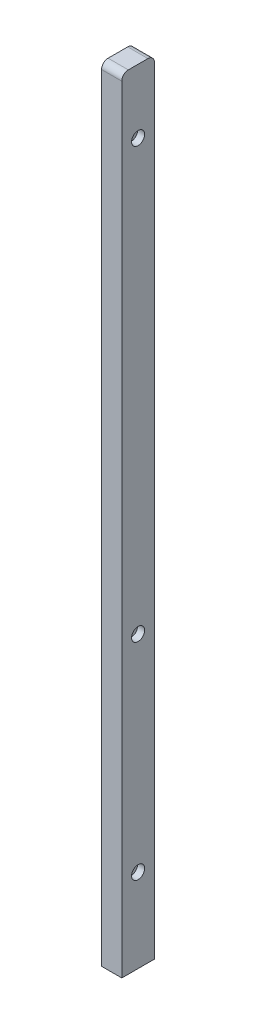
from build123d import *

# Parameters (mm, degrees)
SKETCH1_W                                           = 15.5
SKETCH1_H                                           = 25
BOSS_EXTRUDE1_DEPTH                                 = 600
FILLET1_R                                           = 5
F_5_0MM_DOWEL_HOLE1_D                               = 6.6
F_5_0MM_DOWEL_HOLE1_DEPTH                           = 12
F_5_0MM_DOWEL_HOLE1_TIP                             = 1.982840043
CBORE_FOR_M5_HEX_SOCKET_HEAD_CAP_SCREW1_D           = 5.5
CBORE_FOR_M5_HEX_SOCKET_HEAD_CAP_SCREW1_CBORE_D     = 10
CBORE_FOR_M5_HEX_SOCKET_HEAD_CAP_SCREW1_CBORE_DEPTH = 5.4


with BuildPart() as part:
    # Sketch1 → Boss-Extrude1 (new body)
    with BuildSketch(Plane(origin=(0, 0, 0), x_dir=(1, 0, 0), z_dir=(0, 1, 0))):
        Rectangle(SKETCH1_W, SKETCH1_H)
    extrude(amount=BOSS_EXTRUDE1_DEPTH)

    # Fillet1
    fillet1_edges = [part.edges().sort_by_distance(p)[0] for p in [
        (0, 600, 12.5),
        (0, 600, -12.5),
    ]]
    fillet(fillet1_edges, radius=FILLET1_R)

    # Ø5.0mm Dowel Hole1
    with Locations(Plane(origin=(0, 0, 0), x_dir=(-1, 0, 0), z_dir=(0, -1, 0))):
        with Locations((0, 0)):
            Hole(F_5_0MM_DOWEL_HOLE1_D / 2, depth=F_5_0MM_DOWEL_HOLE1_DEPTH)
            with Locations((0, 0, -(F_5_0MM_DOWEL_HOLE1_DEPTH + F_5_0MM_DOWEL_HOLE1_TIP / 2))):  # 118° drill point
                Cone(0, F_5_0MM_DOWEL_HOLE1_D / 2, F_5_0MM_DOWEL_HOLE1_TIP, mode=Mode.SUBTRACT)

    # CBORE for M5 Hex Socket Head Cap Screw1 (through all)
    with Locations(Plane(origin=(7.75, 0, 0), x_dir=(0, 0, -1), z_dir=(1, 0, 0))):
        with Locations((0, 222), (0, 551), (0, 64)):
            CounterBoreHole(CBORE_FOR_M5_HEX_SOCKET_HEAD_CAP_SCREW1_D / 2, CBORE_FOR_M5_HEX_SOCKET_HEAD_CAP_SCREW1_CBORE_D / 2, CBORE_FOR_M5_HEX_SOCKET_HEAD_CAP_SCREW1_CBORE_DEPTH)


solid = part.part
